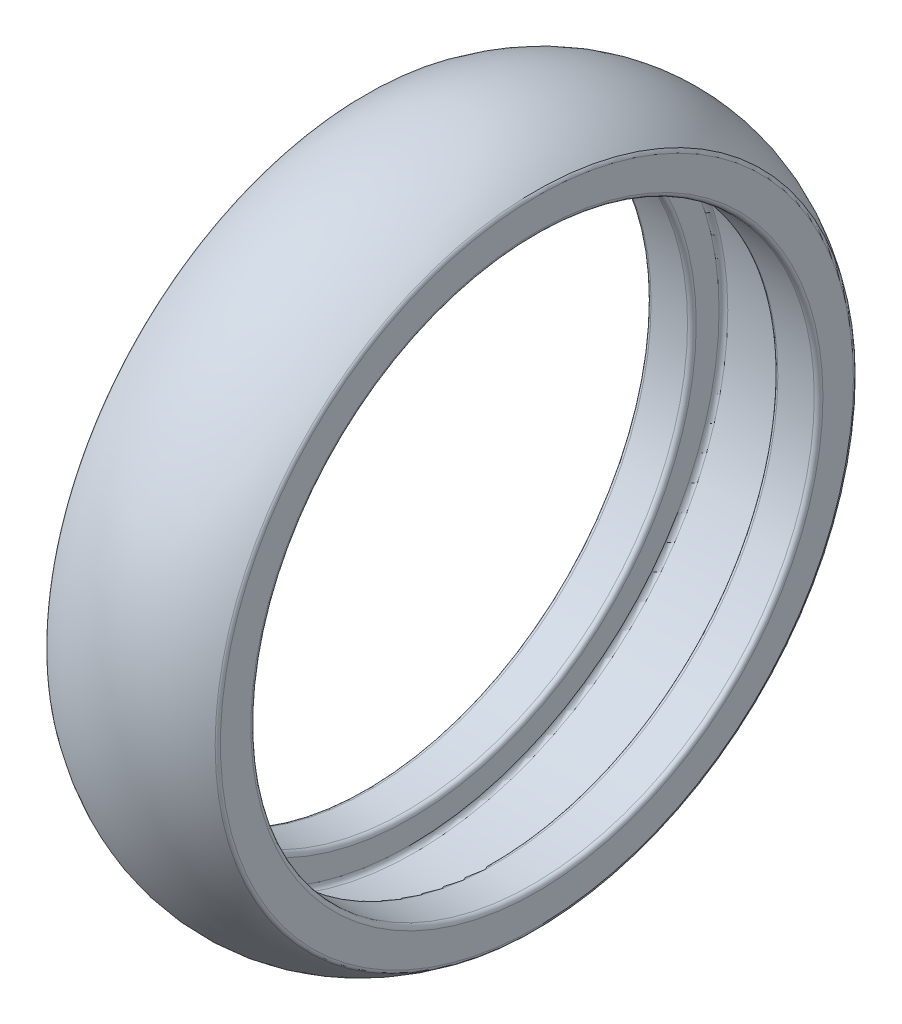
from build123d import *

# Parameters (mm, degrees)
FILLET_1_R = 0.4


with BuildPart() as part:
    # Эскиз1 → Повернуть1 (revolve)
    with BuildSketch(Plane.XY):
        with BuildLine():
            Line((7.9, 25.9), (7.9, 29.299880382))
            ThreePointArc((7.9, 29.299880382), (0, 31.95), (-7.9, 29.299880382))
            Line((-7.9, 29.299880382), (-7.9, 25.9))
            Line((-7.9, 25.9), (-3.75, 25.9))
            Line((-3.75, 25.9), (-3.75, 28.8))
            Line((-3.75, 28.8), (3.75, 28.8))
            Line((3.75, 28.8), (3.75, 25.9))
            Line((3.75, 25.9), (7.9, 25.9))
        make_face()
    revolve(axis=Axis((0, 0, 0), (-1, 0, 0)))

    # Скругление1
    fillet_1_edges = [part.edges().sort_by_distance(p)[0] for p in [
        (-7.9, -29.299880382, 0),
        (7.9, -29.299880382, 0),
        (7.9, -25.9, 0),
        (3.75, -25.9, 0),
        (3.75, -28.8, 0),
        (-3.75, -28.8, 0),
        (-3.75, -25.9, 0),
        (-7.9, -25.9, 0),
    ]]
    fillet(fillet_1_edges, radius=FILLET_1_R)


solid = part.part
